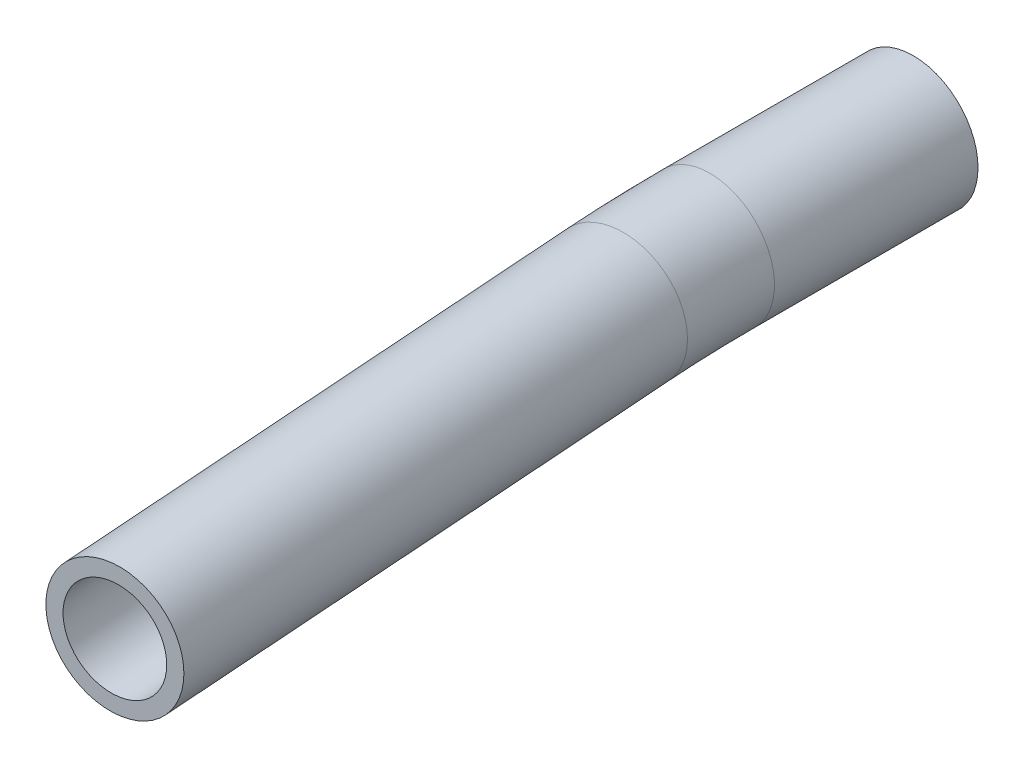
from build123d import *

# Parameters (mm, degrees)
SKETCH_1_R   = 4.765
SKETCH_1_R_2 = 3.58


with BuildPart() as part:
    # По траектории1: sweep along a curve in space
    with BuildLine() as sweep_1_path:
        Line((0, 0, 0), (0, 0, 15))
        ThreePointArc((0, 0, 15), (0.060917298, 0, 18.48994967), (0.243594974, 0, 21.975647374))
        Line((0.243594974, 0, 21.975647374), (3.033853924, 0, 61.878209385))
    # Эскиз1 → По траектории1 (sweep)
    with BuildSketch(Plane.XY):
        Circle(SKETCH_1_R)
        Circle(SKETCH_1_R_2, mode=Mode.SUBTRACT)
    sweep(path=sweep_1_path.line)


solid = part.part
